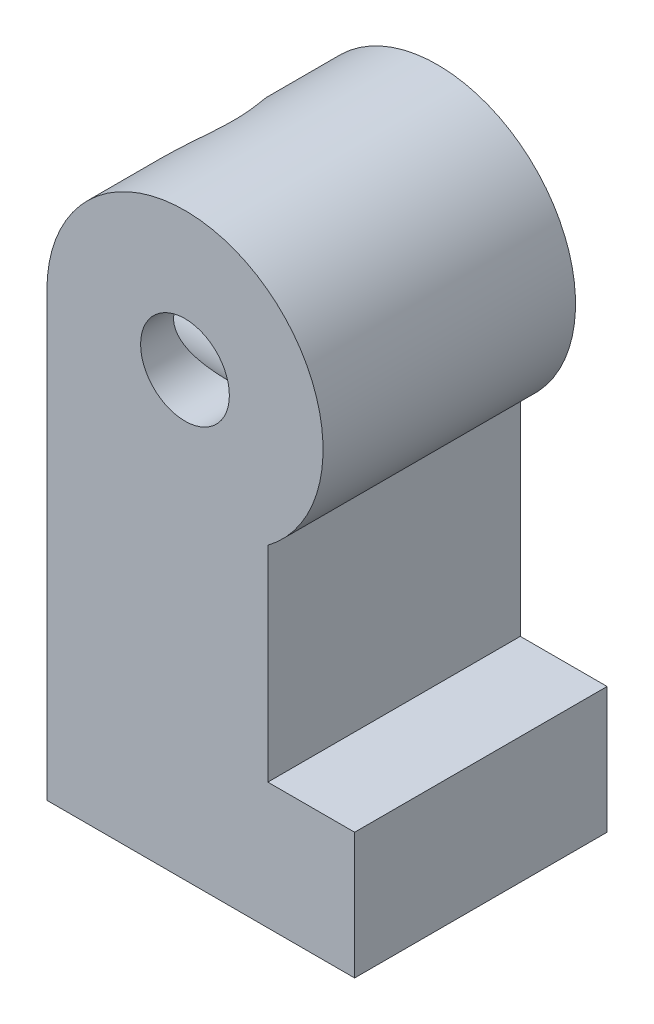
from build123d import *

# Parameters (mm, degrees)
SKETCH1_R           = 1.125
BOSS_EXTRUDE1_DEPTH = 3.2
SKETCH2_W           = 3.3
SKETCH2_H           = 4.8
CUT_EXTRUDE1_DEPTH  = 8.9
SKETCH4_R           = 2.4
CUT_EXTRUDE2_DEPTH  = 5


with BuildPart() as part:
    # Sketch1 → Boss-Extrude1 (new body, symmetric)
    with BuildSketch(Plane.XY):
        with BuildLine():
            Line((-3.5, 0), (-3.5, -11.2))
            Line((-3.5, -11.2), (4.3, -11.2))
            Line((4.3, -11.2), (4.3, -8))
            Line((4.3, -8), (2.1, -8))
            Line((2.1, -8), (2.1, -2.8))
            ThreePointArc((2.1, -2.8), (1.565247584, 3.130495168), (-3.5, 0))
        make_face()
        Circle(SKETCH1_R, mode=Mode.SUBTRACT)
    extrude(amount=BOSS_EXTRUDE1_DEPTH, both=True)

    # Sketch2 → Cut-Extrude1 (cut)
    with BuildSketch(Plane.XZ.offset(11.2)):
        with Locations((-0.45, 0)):
            Rectangle(SKETCH2_W, SKETCH2_H)
    extrude(amount=-CUT_EXTRUDE1_DEPTH, mode=Mode.SUBTRACT)

    # Sketch4 → Cut-Extrude2 (cut)
    with BuildSketch(Plane.ZY.offset(3.5)):
        with Locations((0, 0.5)):
            Circle(SKETCH4_R)
    extrude(amount=-CUT_EXTRUDE2_DEPTH, mode=Mode.SUBTRACT)


solid = part.part
